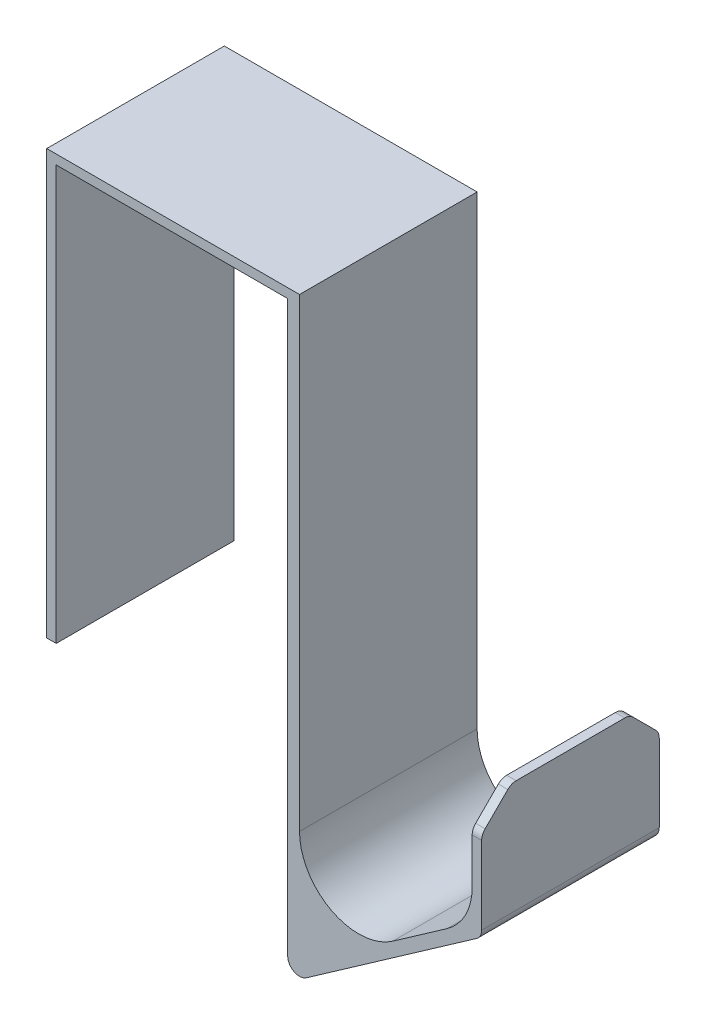
from build123d import *

# Parameters (mm, degrees)
BOSS_EXTRU_1_DEPTH = 30
CONG_1_R           = 10
CHANFREIN1_SIZE    = 5
CONG_2_R           = 2


with BuildPart() as part:
    # Esquisse1 → Boss.-Extru.1 (new body)
    with BuildSketch(Plane.XY):
        Polygon((-19.55, 43.689057372), (-19.55, 113.689057372), (19.55, 113.689057372), (19.55, 13.689057372), (52.316081772, 36.632114826), (52.316081772, 56.632114826), (50.716081772, 56.632114826), (50.716081772, 37.953331942), (21.55, 17.531021626), (21.55, 115.289057372), (-21.15, 115.289057372), (-21.15, 43.689057372), align=None)
    extrude(amount=BOSS_EXTRU_1_DEPTH)

    # Congé1
    cong_1_edges = [part.edges().sort_by_distance(p)[0] for p in [
        (21.55, 17.531021626, 15),
        (50.716081772, 37.953331942, 15),
    ]]
    fillet(cong_1_edges, radius=CONG_1_R)

    # Chanfrein1
    chanfrein1_edges = [part.edges().sort_by_distance(p)[0] for p in [
        (51.516081772, 56.632114826, 0),
        (51.516081772, 56.632114826, 30),
    ]]
    chamfer(chanfrein1_edges, length=CHANFREIN1_SIZE)

    # Congé2
    cong_2_edges = [part.edges().sort_by_distance(p)[0] for p in [
        (52.316081772, 36.632114826, 15),
        (19.55, 13.689057372, 15),
        (51.516081772, 56.632114826, 25),
        (51.516081772, 56.632114826, 5),
        (51.516081772, 51.632114826, 0),
        (51.516081772, 51.632114826, 30),
    ]]
    fillet(cong_2_edges, radius=CONG_2_R)


solid = part.part
